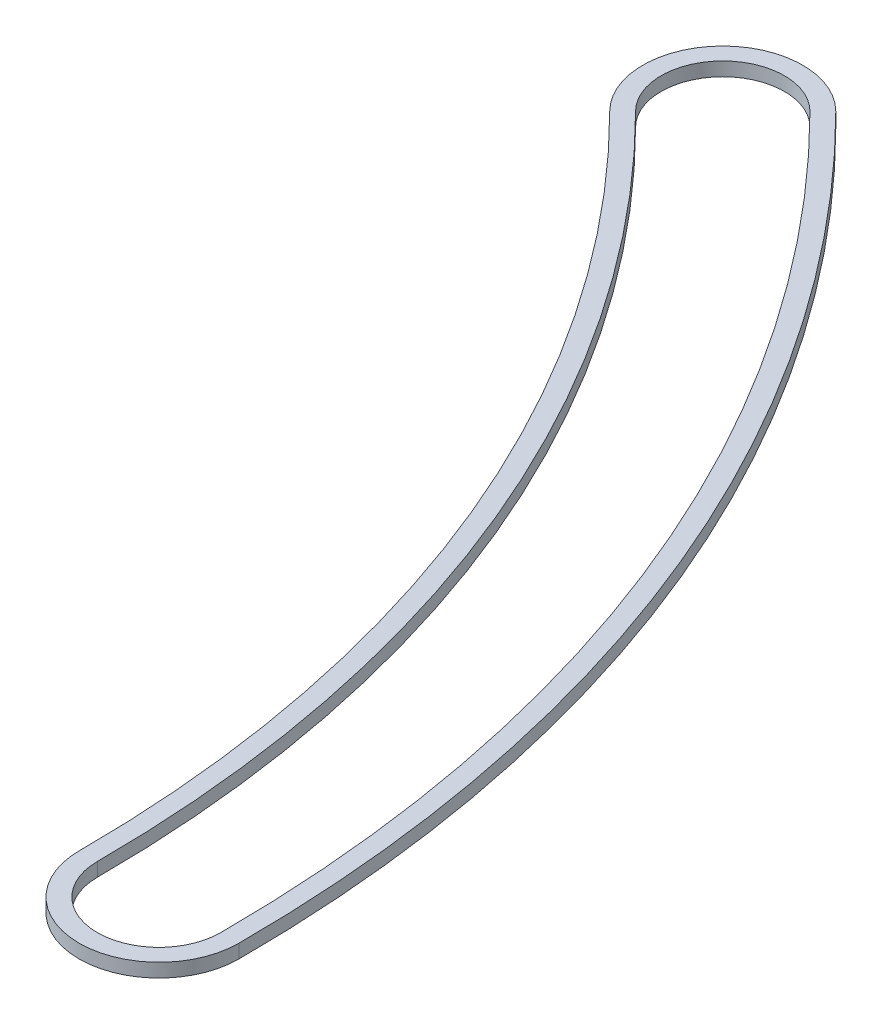
from build123d import *

# Parameters (mm, degrees)
BOSS_EXTRUDE1_DEPTH = 0.762


with BuildPart() as part:
    # Sketch1 → Boss-Extrude1 (new body)
    with BuildSketch(Plane(origin=(0, 0, 0), x_dir=(1, 0, 0), z_dir=(0, 1, 0))):
        with BuildLine():
            ThreePointArc((80.137, 0), (74.036934097, 30.667102219), (56.665416124, 56.665416124))
            ThreePointArc((56.665416124, 56.665416124), (50.379236839, 56.665416124), (50.379236839, 50.379236839))
            ThreePointArc((50.379236839, 50.379236839), (65.823645053, 27.265046506), (71.247, 0))
            ThreePointArc((71.247, 0), (75.692, -4.445), (80.137, 0))
        make_face()
        with BuildLine():
            ThreePointArc((79.121, 0), (73.098272492, 30.278295852), (55.946995634, 55.946995634))
            ThreePointArc((55.946995634, 55.946995634), (51.097657329, 55.946995634), (51.097657329, 51.097657329))
            ThreePointArc((51.097657329, 51.097657329), (66.762306658, 27.653852873), (72.263, 0))
            ThreePointArc((72.263, 0), (75.692, -3.429), (79.121, 0))
        make_face(mode=Mode.SUBTRACT)
    extrude(amount=BOSS_EXTRUDE1_DEPTH)


solid = part.part
